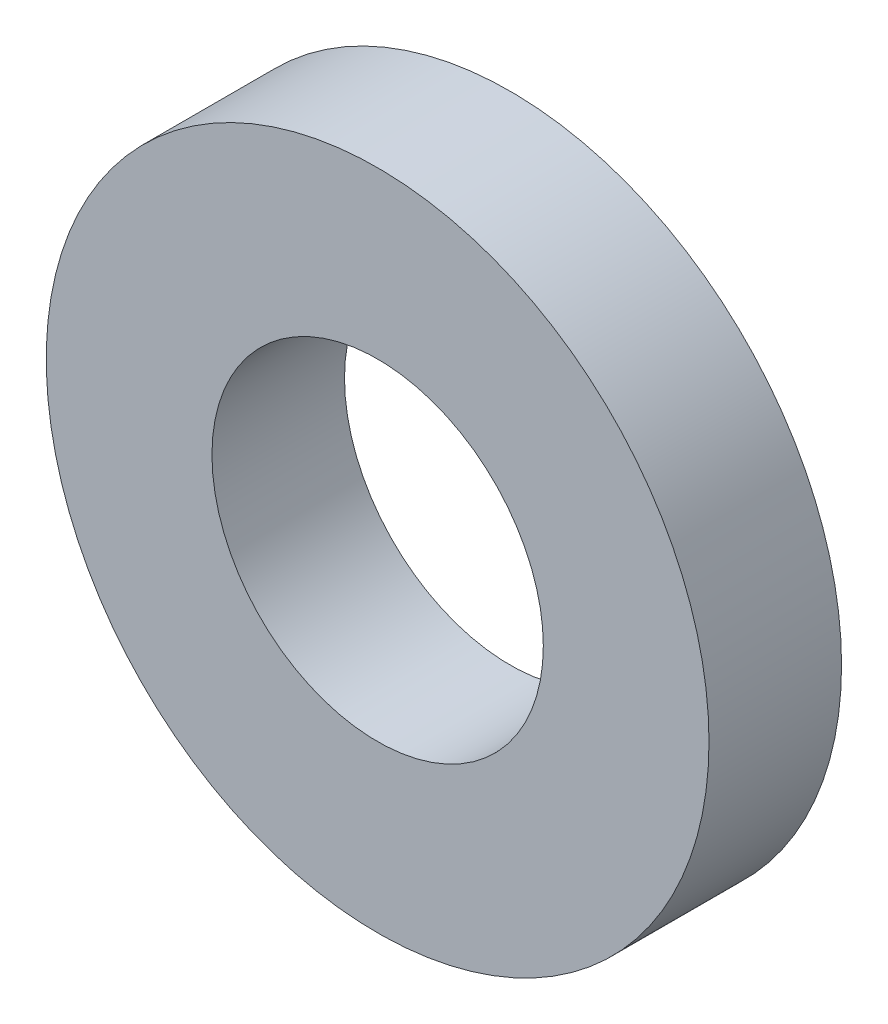
from build123d import *

# Parameters (mm, degrees)
SKETCH1_R           = 2.5
SKETCH1_R_2         = 1.25
BOSS_EXTRUDE1_DEPTH = 1


with BuildPart() as part:
    # Sketch1 → Boss-Extrude1 (new body)
    with BuildSketch(Plane.XY):
        Circle(SKETCH1_R)
        Circle(SKETCH1_R_2, mode=Mode.SUBTRACT)
    extrude(amount=BOSS_EXTRUDE1_DEPTH)


solid = part.part
